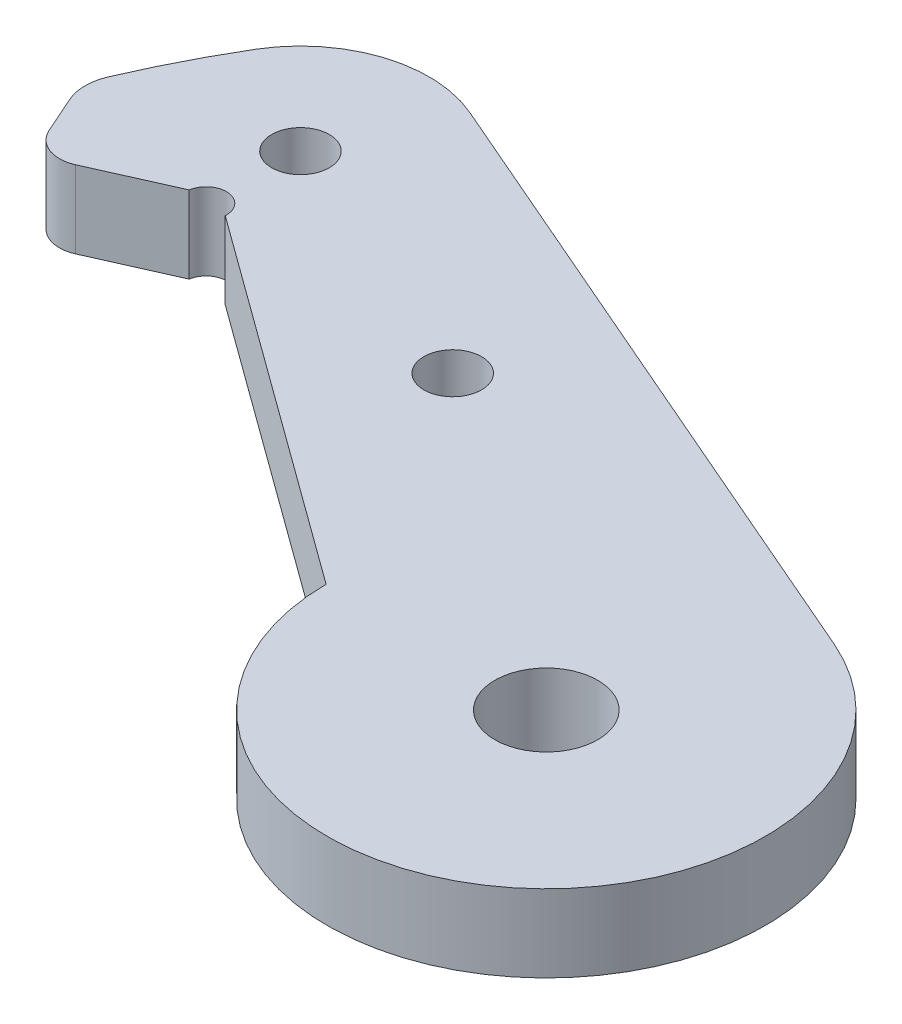
from build123d import *

# Parameters (mm, degrees)
SKETCH1_R           = 1.778
SKETCH1_R_2         = 3.175
BOSS_EXTRUDE1_DEPTH = 4.7625


with BuildPart() as part:
    # Sketch1 → Boss-Extrude1 (new body)
    with BuildSketch(Plane(origin=(0, 0, 0), x_dir=(1, 0, 0), z_dir=(0, 1, 0))):
        with BuildLine():
            Line((-38.770225031, 16.757963615), (-43.625448569, 14.598747375))
            ThreePointArc((-43.625448569, 14.598747375), (-45.155674622, 14.559326862), (-46.265582353, 15.613485569))
            Line((-46.265582353, 15.613485569), (-47.282683039, 17.900542834))
            ThreePointArc((-47.282683039, 17.900542834), (-47.541465806, 19.100109045), (-47.298283286, 20.302934833))
            ThreePointArc((-47.298283286, 20.302934833), (-45.865213893, 23.360627542), (-44.234733225, 26.317772344))
            ThreePointArc((-44.234733225, 26.317772344), (-39.855484626, 29.811728531), (-34.259632886, 29.543416329))
            Line((-34.259632886, 29.543416329), (5.363638877, 12.388760148))
            ThreePointArc((5.363638877, 12.388760148), (7.44200849, -11.263503435), (-13.499793526, -0.074664302))
            Line((-13.499793526, -0.074664302), (-36.286855081, 16.495885282))
            ThreePointArc((-36.286855081, 16.495885282), (-37.403602541, 17.810792136), (-38.770225031, 16.757963615))
        make_face()
        with Locations((-20.862458922, 15.093717491)):
            Circle(SKETCH1_R, mode=Mode.SUBTRACT)
        Circle(SKETCH1_R_2, mode=Mode.SUBTRACT)
        with Locations((-37.413253893, 22.259284205)):
            Circle(SKETCH1_R, mode=Mode.SUBTRACT)
    extrude(amount=BOSS_EXTRUDE1_DEPTH)


solid = part.part
